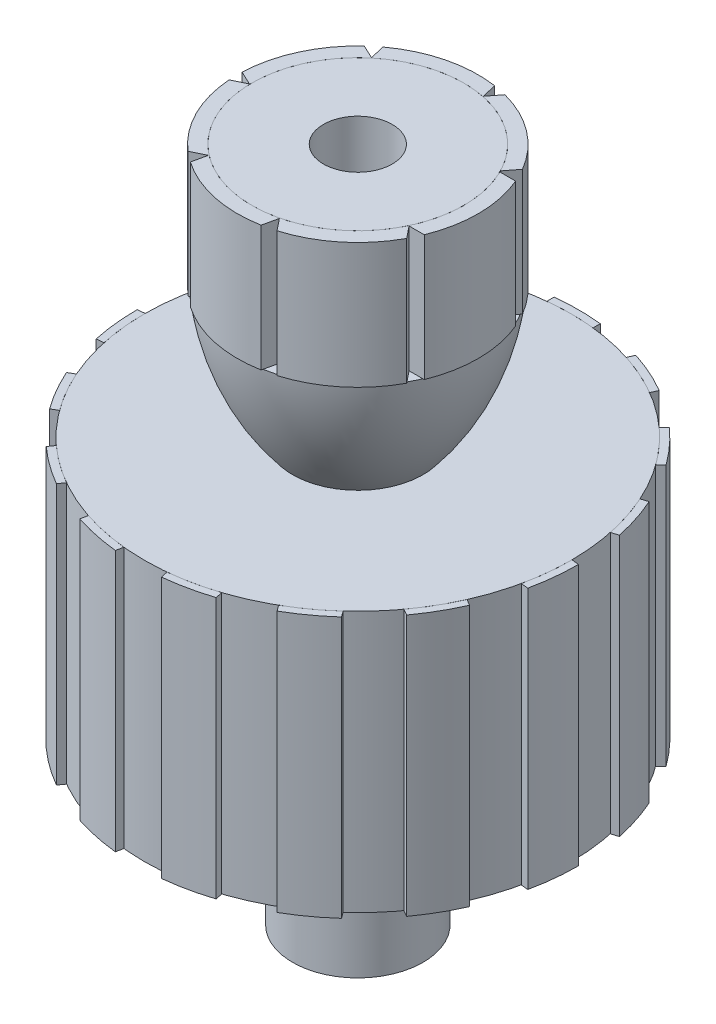
from build123d import *

# Parameters (mm, degrees)
SKETCH2_R               = 3.175
CUT_EXTRUDE1_DEPTH      = 1
CUT_EXTRUDE1_DEPTH_BACK = 58.8612
BOSS_EXTRUDE2_DEPTH     = 24.1046
BOSS_EXTRUDE2_2_DEPTH   = 24.1046
BOSS_EXTRUDE2_3_DEPTH   = 24.1046
BOSS_EXTRUDE2_4_DEPTH   = 24.1046
BOSS_EXTRUDE2_5_DEPTH   = 24.1046
BOSS_EXTRUDE2_6_DEPTH   = 24.1046
BOSS_EXTRUDE2_7_DEPTH   = 24.1046
BOSS_EXTRUDE2_8_DEPTH   = 24.1046
BOSS_EXTRUDE2_9_DEPTH   = 24.1046
BOSS_EXTRUDE2_10_DEPTH  = 24.1046
BOSS_EXTRUDE2_11_DEPTH  = 24.1046
BOSS_EXTRUDE2_12_DEPTH  = 24.1046
BOSS_EXTRUDE2_13_DEPTH  = 24.1046
BOSS_EXTRUDE2_14_DEPTH  = 24.1046
BOSS_EXTRUDE2_15_DEPTH  = 24.1046
BOSS_EXTRUDE4_DEPTH     = 11.5824
BOSS_EXTRUDE4_2_DEPTH   = 11.5824
SKETCH7_R               = 6.02698233
SKETCH7_R_2             = 3.175
BOSS_EXTRUDE5_DEPTH     = 4.5593


with BuildPart() as part:
    # Sketch1 → Revolve1 (revolve)
    with BuildSketch(Plane.XY):
        Polygon((3.398475252, -22.190292446), (0, -22.190292446), (0, 35.670907554), (9.7917, 35.670907554), (9.7917, 24.088507554), (6.02698233, 24.088507554), (6.02698233, 12.252107554), (19.709387233, 12.252107554), (19.709387233, -11.852492446), (6.02698233, -11.852492446), (6.02698233, -22.190292446), align=None)
    revolve(axis=Axis((0, -22.190292446, 0), (0, 1, 0)))

    # Sketch2 → Cut-Extrude1 (cut, two sides)
    with BuildSketch(Plane.XZ.offset(22.190292446)) as cut_extrude1_sk:
        Circle(SKETCH2_R)
    extrude(amount=CUT_EXTRUDE1_DEPTH, mode=Mode.SUBTRACT)
    extrude(cut_extrude1_sk.sketch, amount=-CUT_EXTRUDE1_DEPTH_BACK, mode=Mode.SUBTRACT)

    # Sketch7 → Boss-Extrude5 (add)
    with BuildSketch(Plane.XZ.offset(22.190292446)):
        Circle(SKETCH7_R)
        Circle(SKETCH7_R_2, mode=Mode.SUBTRACT)
    extrude(amount=BOSS_EXTRUDE5_DEPTH)


with BuildPart() as body_2:
    # Sketch3 → Boss-Extrude2 (new body)
    with BuildSketch(Plane.XZ.offset(11.852492446)):
        with BuildLine():
            Line((2.129978383, -20.26539062), (2.129978383, -19.59395665))
            ThreePointArc((2.129978383, -19.59395665), (0, -19.709387233), (-2.129978383, -19.59395665))
            Line((-2.129978383, -19.59395665), (-2.129978383, -20.26539062))
            ThreePointArc((-2.129978383, -20.26539062), (0, -20.377018057), (2.129978383, -20.26539062))
        make_face()
    extrude(amount=-BOSS_EXTRUDE2_DEPTH)


with BuildPart() as body_3:
    # Sketch3 → Boss-Extrude2 2 (new body)
    with BuildSketch(Plane.XZ.offset(11.852492446)):
        with BuildLine():
            Line((-6.296844874, -19.379695806), (-6.023748075, -18.766310352))
            ThreePointArc((-6.023748075, -18.766310352), (-8.01653, -18.00542118), (-9.915412229, -17.033629837))
            Line((-9.915412229, -17.033629837), (-10.188509029, -17.647015291))
            ThreePointArc((-10.188509029, -17.647015291), (-8.28807992, -18.615332286), (-6.296844874, -19.379695806))
        make_face()
    extrude(amount=-BOSS_EXTRUDE2_2_DEPTH)


with BuildPart() as body_4:
    # Sketch3 → Boss-Extrude2 3 (new body)
    with BuildSketch(Plane.XZ.offset(11.852492446)):
        with BuildLine():
            Line((-13.634886448, -15.143075528), (-13.135913768, -14.693798508))
            ThreePointArc((-13.135913768, -14.693798508), (-14.646929136, -13.18815423), (-15.986381222, -11.52803368))
            Line((-15.986381222, -11.52803368), (-16.485353903, -11.9773107))
            ThreePointArc((-16.485353903, -11.9773107), (-15.143075528, -13.634886448), (-13.634886448, -15.143075528))
        make_face()
    extrude(amount=-BOSS_EXTRUDE2_3_DEPTH)


with BuildPart() as body_5:
    # Sketch3 → Boss-Extrude2 4 (new body)
    with BuildSketch(Plane.XZ.offset(11.852492446)):
        with BuildLine():
            Line((-18.615332286, -8.28807992), (-17.976760633, -8.080595413))
            ThreePointArc((-17.976760633, -8.080595413), (-18.74474116, -6.090535604), (-19.29315967, -4.029135771))
            Line((-19.29315967, -4.029135771), (-19.931731323, -4.236620278))
            ThreePointArc((-19.931731323, -4.236620278), (-19.379695806, -6.296844874), (-18.615332286, -8.28807992))
        make_face()
    extrude(amount=-BOSS_EXTRUDE2_4_DEPTH)


with BuildPart() as body_6:
    # Sketch3 → Boss-Extrude2 5 (new body)
    with BuildSketch(Plane.XZ.offset(11.852492446)):
        with BuildLine():
            Line((-20.377018057, 0), (-19.709262272, -0.070183961))
            ThreePointArc((-19.709262272, -0.070183961), (-19.601417148, 2.060191959), (-19.263975538, 4.166436317))
            Line((-19.263975538, 4.166436317), (-19.931731323, 4.236620278))
            ThreePointArc((-19.931731323, 4.236620278), (-20.26539062, 2.129978383), (-20.377018057, 0))
        make_face()
    extrude(amount=-BOSS_EXTRUDE2_5_DEPTH)


with BuildPart() as body_7:
    # Sketch3 → Boss-Extrude2 6 (new body)
    with BuildSketch(Plane.XZ.offset(11.852492446)):
        with BuildLine():
            Line((-18.615332286, 8.28807992), (-18.033853411, 7.952362935))
            ThreePointArc((-18.033853411, 7.952362935), (-17.068830037, 9.854693617), (-15.903875027, 11.641593714))
            Line((-15.903875027, 11.641593714), (-16.485353903, 11.9773107))
            ThreePointArc((-16.485353903, 11.9773107), (-17.647015291, 10.188509029), (-18.615332286, 8.28807992))
        make_face()
    extrude(amount=-BOSS_EXTRUDE2_6_DEPTH)


with BuildPart() as body_8:
    # Sketch3 → Boss-Extrude2 7 (new body)
    with BuildSketch(Plane.XZ.offset(11.852492446)):
        with BuildLine():
            Line((-13.634886448, 15.143075528), (-13.240227463, 14.599874035))
            ThreePointArc((-13.240227463, 14.599874035), (-11.584887147, 15.94522922), (-9.793850043, 17.103813798))
            Line((-9.793850043, 17.103813798), (-10.188509029, 17.647015291))
            ThreePointArc((-10.188509029, 17.647015291), (-11.9773107, 16.485353903), (-13.634886448, 15.143075528))
        make_face()
    extrude(amount=-BOSS_EXTRUDE2_7_DEPTH)


with BuildPart() as body_9:
    # Sketch3 → Boss-Extrude2 8 (new body)
    with BuildSketch(Plane.XZ.offset(11.852492446)):
        with BuildLine():
            Line((-6.296844874, 19.379695806), (-6.157245902, 18.722934279))
            ThreePointArc((-6.157245902, 18.722934279), (-4.097812025, 19.278689834), (-1.990379411, 19.608629093))
            Line((-1.990379411, 19.608629093), (-2.129978383, 20.26539062))
            ThreePointArc((-2.129978383, 20.26539062), (-4.236620278, 19.931731323), (-6.296844874, 19.379695806))
        make_face()
    extrude(amount=-BOSS_EXTRUDE2_8_DEPTH)


with BuildPart() as body_10:
    # Sketch3 → Boss-Extrude2 9 (new body)
    with BuildSketch(Plane.XZ.offset(11.852492446)):
        with BuildLine():
            Line((2.129978383, 20.26539062), (1.990379411, 19.608629093))
            ThreePointArc((1.990379411, 19.608629093), (4.097812025, 19.278689834), (6.157245902, 18.722934279))
            Line((6.157245902, 18.722934279), (6.296844874, 19.379695806))
            ThreePointArc((6.296844874, 19.379695806), (4.236620278, 19.931731323), (2.129978383, 20.26539062))
        make_face()
    extrude(amount=-BOSS_EXTRUDE2_9_DEPTH)


with BuildPart() as body_11:
    # Sketch3 → Boss-Extrude2 10 (new body)
    with BuildSketch(Plane.XZ.offset(11.852492446)):
        with BuildLine():
            Line((10.188509029, 17.647015291), (9.793850043, 17.103813798))
            ThreePointArc((9.793850043, 17.103813798), (11.584887147, 15.94522922), (13.240227463, 14.599874035))
            Line((13.240227463, 14.599874035), (13.634886448, 15.143075528))
            ThreePointArc((13.634886448, 15.143075528), (11.9773107, 16.485353903), (10.188509029, 17.647015291))
        make_face()
    extrude(amount=-BOSS_EXTRUDE2_10_DEPTH)


with BuildPart() as body_12:
    # Sketch3 → Boss-Extrude2 11 (new body)
    with BuildSketch(Plane.XZ.offset(11.852492446)):
        with BuildLine():
            Line((16.485353903, 11.9773107), (15.903875027, 11.641593714))
            ThreePointArc((15.903875027, 11.641593714), (17.068830037, 9.854693617), (18.033853411, 7.952362935))
            Line((18.033853411, 7.952362935), (18.615332286, 8.28807992))
            ThreePointArc((18.615332286, 8.28807992), (17.647015291, 10.188509029), (16.485353903, 11.9773107))
        make_face()
    extrude(amount=-BOSS_EXTRUDE2_11_DEPTH)


with BuildPart() as body_13:
    # Sketch3 → Boss-Extrude2 12 (new body)
    with BuildSketch(Plane.XZ.offset(11.852492446)):
        with BuildLine():
            Line((19.931731323, 4.236620278), (19.263975538, 4.166436317))
            ThreePointArc((19.263975538, 4.166436317), (19.601417148, 2.060191959), (19.709262272, -0.070183961))
            Line((19.709262272, -0.070183961), (20.377018057, 0))
            ThreePointArc((20.377018057, 0), (20.26539062, 2.129978383), (19.931731323, 4.236620278))
        make_face()
    extrude(amount=-BOSS_EXTRUDE2_12_DEPTH)


with BuildPart() as body_14:
    # Sketch3 → Boss-Extrude2 13 (new body)
    with BuildSketch(Plane.XZ.offset(11.852492446)):
        with BuildLine():
            Line((19.931731323, -4.236620278), (19.29315967, -4.029135771))
            ThreePointArc((19.29315967, -4.029135771), (18.74474116, -6.090535604), (17.976760633, -8.080595413))
            Line((17.976760633, -8.080595413), (18.615332286, -8.28807992))
            ThreePointArc((18.615332286, -8.28807992), (19.379695806, -6.296844874), (19.931731323, -4.236620278))
        make_face()
    extrude(amount=-BOSS_EXTRUDE2_13_DEPTH)


with BuildPart() as body_15:
    # Sketch3 → Boss-Extrude2 14 (new body)
    with BuildSketch(Plane.XZ.offset(11.852492446)):
        with BuildLine():
            Line((16.485353903, -11.9773107), (15.986381222, -11.52803368))
            ThreePointArc((15.986381222, -11.52803368), (14.646929136, -13.18815423), (13.135913768, -14.693798508))
            Line((13.135913768, -14.693798508), (13.634886448, -15.143075528))
            ThreePointArc((13.634886448, -15.143075528), (15.143075528, -13.634886448), (16.485353903, -11.9773107))
        make_face()
    extrude(amount=-BOSS_EXTRUDE2_14_DEPTH)


with BuildPart() as body_16:
    # Sketch3 → Boss-Extrude2 15 (new body)
    with BuildSketch(Plane.XZ.offset(11.852492446)):
        with BuildLine():
            Line((10.188509029, -17.647015291), (9.915412229, -17.033629837))
            ThreePointArc((9.915412229, -17.033629837), (8.01653, -18.00542118), (6.023748075, -18.766310352))
            Line((6.023748075, -18.766310352), (6.296844874, -19.379695806))
            ThreePointArc((6.296844874, -19.379695806), (8.28807992, -18.615332286), (10.188509029, -17.647015291))
        make_face()
    extrude(amount=-BOSS_EXTRUDE2_15_DEPTH)


with BuildPart() as body_17:
    # Sketch4 → Boss-Extrude4 (new body)
    with BuildSketch(Plane(origin=(0, 35.670907554, 0), x_dir=(1, 0, 0), z_dir=(0, 1, 0))):
        with BuildLine():
            Line((10.237362125, 4.338695071), (8.777990315, 4.338695071))
            ThreePointArc((8.777990315, 4.338695071), (2.324089523, -9.51188713), (-9.789696969, -0.19804584))
            Line((-9.789696969, -0.19804584), (-9.830682257, -0.178809531))
            Line((-9.830682257, -0.178809531), (-11.090204264, -0.79701165))
            ThreePointArc((-11.090204264, -0.79701165), (-9.941009577, -4.980380184), (-7.278386297, -8.405530982))
            Line((-7.278386297, -8.405530982), (-6.008954103, -7.782464717))
            Line((-6.008954103, -7.782464717), (-6.314338707, -9.151884226))
            ThreePointArc((-6.314338707, -9.151884226), (-2.331413825, -10.87163133), (2.006447678, -10.936271115))
            Line((2.006447678, -10.936271115), (2.314235113, -9.556076723))
            Line((2.314235113, -9.556076723), (3.191759322, -10.650846474))
            ThreePointArc((3.191759322, -10.650846474), (7.024703597, -8.618665649), (9.788200428, -5.274371107))
            Line((9.788200428, -5.274371107), (8.903771672, -4.170987474))
            Line((8.903771672, -4.170987474), (10.306828886, -4.170987474))
            ThreePointArc((10.306828886, -4.170987474), (11.118436056, 0.090762698), (10.237362125, 4.338695071))
        make_face()
    extrude(amount=-BOSS_EXTRUDE4_DEPTH)


with BuildPart() as body_18:
    # Sketch4 → Boss-Extrude4 2 (new body)
    with BuildSketch(Plane(origin=(0, 35.670907554, 0), x_dir=(1, 0, 0), z_dir=(0, 1, 0))):
        with BuildLine():
            Line((8.718756713, 4.456531193), (9.604485053, 5.601939402))
            ThreePointArc((9.604485053, 5.601939402), (6.729617762, 8.850994462), (2.830227172, 10.752565849))
            Line((2.830227172, 10.752565849), (1.965189818, 9.633914857))
            Line((1.965189818, 9.633914857), (1.635952059, 10.9977961))
            ThreePointArc((1.635952059, 10.9977961), (-2.697251736, 10.786690468), (-6.619823405, 8.933408995))
            Line((-6.619823405, 8.933408995), (-6.287995134, 7.558796444))
            Line((-6.287995134, 7.558796444), (-7.558114424, 8.154922718))
            ThreePointArc((-7.558114424, 8.154922718), (-10.103541037, 4.641801018), (-11.110795116, 0.422007192))
            Line((-11.110795116, 0.422007192), (-9.830682257, -0.178809531))
            Line((-9.830682257, -0.178809531), (-9.79040829, -0.15904215))
            ThreePointArc((-9.79040829, -0.15904215), (-2.369174665, 9.50075788), (8.718756713, 4.456531193))
        make_face()
    extrude(amount=-BOSS_EXTRUDE4_2_DEPTH)


with BuildPart() as body_19:
    # Sketch6 → Revolve7 (revolve)
    with BuildSketch(Plane(origin=(0, 0, 0), x_dir=(0, 0, -1), z_dir=(1, 0, 0))):
        with BuildLine():
            ThreePointArc((10.9977961, 24.088507554), (9.371632058, 17.809459986), (6.02698233, 12.252107554))
            Line((6.02698233, 12.252107554), (6.02698233, 24.088507554))
            Line((6.02698233, 24.088507554), (10.9977961, 24.088507554))
        make_face()
        with BuildLine():
            Line((6.02698233, -11.852492446), (6.02698233, -19.887424982))
            ThreePointArc((6.02698233, -19.887424982), (12.15425901, -16.91231972), (16.714184315, -11.852492446))
            Line((16.714184315, -11.852492446), (6.02698233, -11.852492446))
        make_face()
    revolve(axis=Axis((0, 0, 0), (0, 1, 0)))


solid = Compound([part.part, body_2.part, body_3.part, body_4.part, body_5.part, body_6.part, body_7.part, body_8.part, body_9.part, body_10.part, body_11.part, body_12.part, body_13.part, body_14.part, body_15.part, body_16.part, body_17.part, body_18.part, body_19.part])
